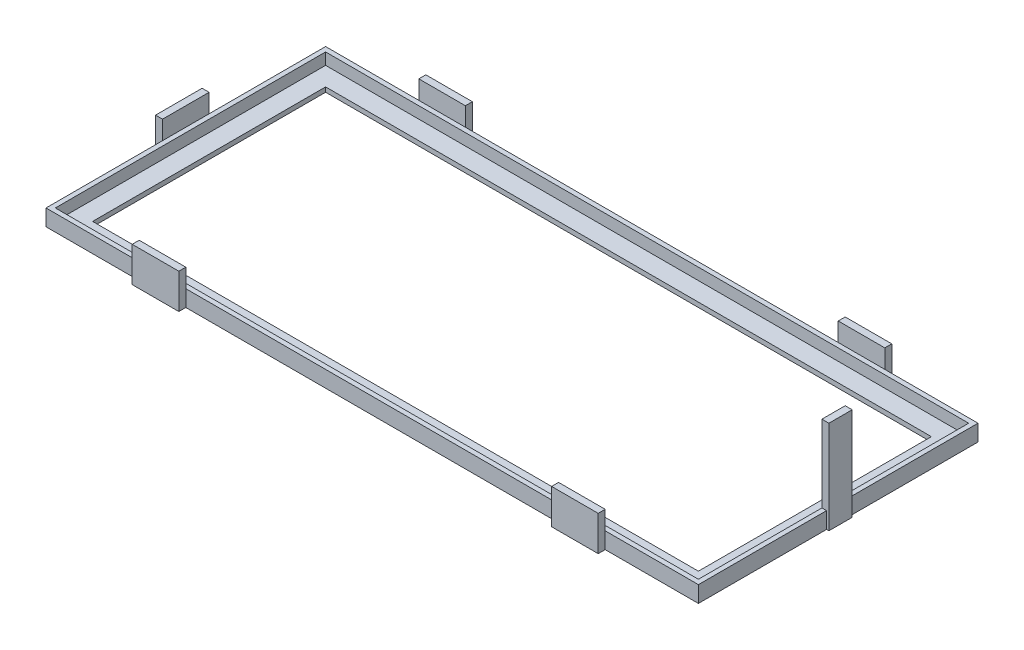
from build123d import *

# Parameters (mm, degrees)
SKETCH1_W           = 280
SKETCH1_H           = 120
BOSS_EXTRUDE1_DEPTH = 2
SKETCH2_W           = 280
SKETCH2_H           = 120
SKETCH2_W_2         = 276
SKETCH2_H_2         = 116
BOSS_EXTRUDE2_DEPTH = 5
SKETCH4_W           = 20
SKETCH4_H           = 3
SKETCH4_W_2         = 3
SKETCH4_H_2         = 20
BOSS_EXTRUDE3_DEPTH = 15
SKETCH5_W           = 3
SKETCH5_H           = 10
BOSS_EXTRUDE4_DEPTH = 40
SKETCH6_W           = 260
SKETCH6_H           = 100
CUT_EXTRUDE2_DEPTH  = 41


with BuildPart() as part:
    # Sketch1 → Boss-Extrude1 (new body)
    with BuildSketch(Plane(origin=(0, 0, 0), x_dir=(1, 0, 0), z_dir=(0, 1, 0))):
        with Locations((140, -60)):
            Rectangle(SKETCH1_W, SKETCH1_H)
    extrude(amount=BOSS_EXTRUDE1_DEPTH)

    # Sketch2 → Boss-Extrude2 (add)
    with BuildSketch(Plane(origin=(0, 2, 0), x_dir=(1, 0, 0), z_dir=(0, 1, 0))):
        with Locations((140, -60)):
            Rectangle(SKETCH2_W, SKETCH2_H)
        with Locations((140, -60)):
            Rectangle(SKETCH2_W_2, SKETCH2_H_2, mode=Mode.SUBTRACT)
    extrude(amount=BOSS_EXTRUDE2_DEPTH)

    # Sketch4 → Boss-Extrude3 (add)
    with BuildSketch(Plane(origin=(0, 0, 0), x_dir=(-1, 0, 0), z_dir=(0, -1, 0))):
        with Locations((-50, 1.5)):
            Rectangle(SKETCH4_W, SKETCH4_H)
        with Locations((-230, 1.5)):
            Rectangle(SKETCH4_W, SKETCH4_H)
        with Locations((-230, -121.5)):
            Rectangle(SKETCH4_W, SKETCH4_H)
        with Locations((-50, -121.5)):
            Rectangle(SKETCH4_W, SKETCH4_H)
        with Locations((1.5, -60)):
            Rectangle(SKETCH4_W_2, SKETCH4_H_2)
    extrude(amount=-BOSS_EXTRUDE3_DEPTH)

    # Sketch5 → Boss-Extrude4 (add)
    with BuildSketch(Plane(origin=(0, 0, 0), x_dir=(-1, 0, 0), z_dir=(0, -1, 0))):
        with Locations((-279.5, -60)):
            Rectangle(SKETCH5_W, SKETCH5_H)
    extrude(amount=-BOSS_EXTRUDE4_DEPTH)

    # Sketch6 → Cut-Extrude2 (cut, through all)
    with BuildSketch(Plane(origin=(0, 0, 0), x_dir=(-1, 0, 0), z_dir=(0, -1, 0))):
        with Locations((-140, -60)):
            Rectangle(SKETCH6_W, SKETCH6_H)
    extrude(amount=-CUT_EXTRUDE2_DEPTH, mode=Mode.SUBTRACT)


solid = part.part
